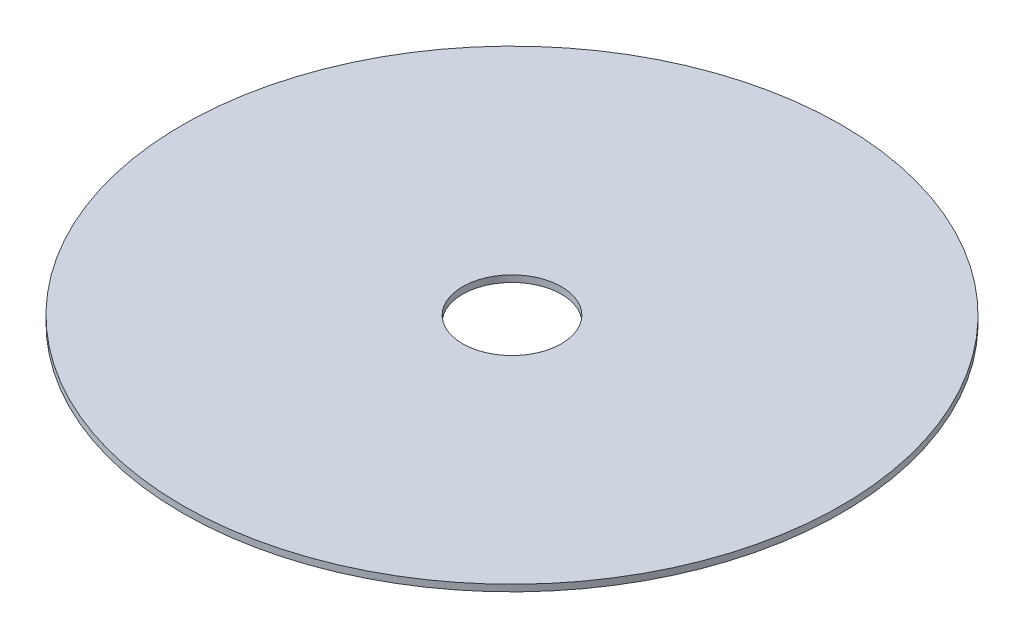
from build123d import *

# Parameters (mm, degrees)
SKETCH1_R           = 60
SKETCH1_R_2         = 9
BOSS_EXTRUDE1_DEPTH = 1.2


with BuildPart() as part:
    # Sketch1 → Boss-Extrude1 (new body)
    with BuildSketch(Plane(origin=(0, 0, 0), x_dir=(1, 0, 0), z_dir=(0, 1, 0))):
        Circle(SKETCH1_R)
        Circle(SKETCH1_R_2, mode=Mode.SUBTRACT)
    extrude(amount=BOSS_EXTRUDE1_DEPTH)


solid = part.part
